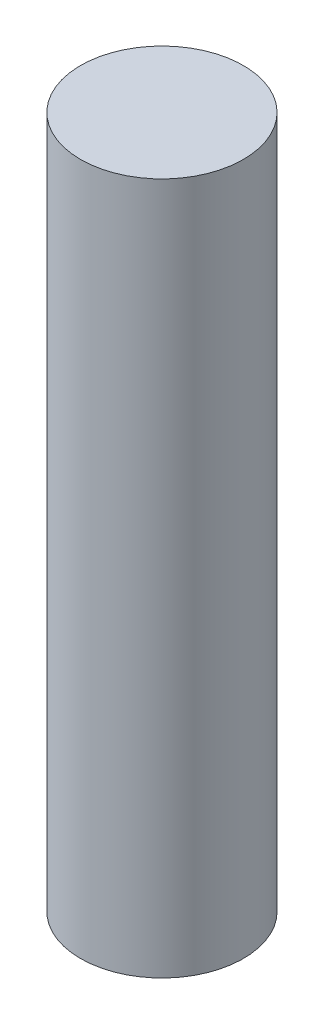
from build123d import *

# Parameters (mm, degrees)
SKETCH1_R           = 20
BOSS_EXTRUDE1_DEPTH = 170


with BuildPart() as part:
    # Sketch1 → Boss-Extrude1 (new body)
    with BuildSketch(Plane(origin=(0, 0, 0), x_dir=(1, 0, 0), z_dir=(0, 1, 0))):
        Circle(SKETCH1_R)
    extrude(amount=BOSS_EXTRUDE1_DEPTH)


solid = part.part
